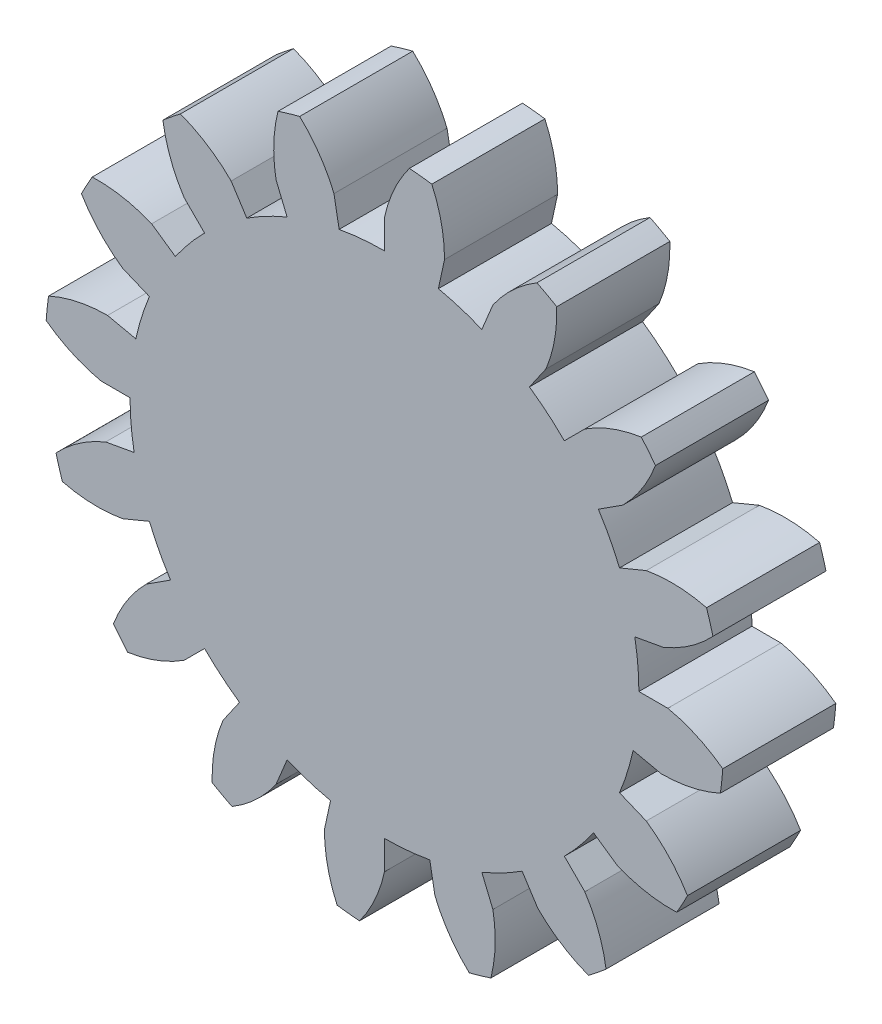
from build123d import *

# Parameters (mm, degrees)
BOSS_EXTRU_1_DEPTH           = 3
R_P_TITION_CIRCULAIRE2_COUNT = 16
ESQUISSE5_R                  = 6.75
BOSS_EXTRU_2_DEPTH           = 3


with BuildPart() as part:
    # Esquisse4 → Boss.-Extru.1 (new body)
    with BuildSketch(Plane.XY):
        with BuildLine():
            Line((0, 7.517540966), (0, 6.75))
            ThreePointArc((0, 6.75), (0.719454333, 6.711548664), (1.430711931, 6.59663273))
            Line((1.430711931, 6.59663273), (1.593397859, 7.346734339))
            ThreePointArc((1.593397859, 7.346734339), (1.508511555, 8.147299885), (1.256427196, 8.911867969))
            ThreePointArc((1.256427196, 8.911867969), (0.959272444, 8.948731551), (0.661055861, 8.975689675))
            ThreePointArc((0.661055861, 8.975689675), (0.252643326, 8.281924527), (0, 7.517540966))
        make_face()
    extrude(amount=BOSS_EXTRU_1_DEPTH)


with BuildPart() as r_p_tition_circulaire2_1:
    # Répétition circulaire2: pattern copy
    add(part.part.rotate(Axis((0, 0, 0), (0, 0, 1)), 1 * 360 / R_P_TITION_CIRCULAIRE2_COUNT))


with BuildPart() as r_p_tition_circulaire2_2:
    # Répétition circulaire2: pattern copy
    add(part.part.rotate(Axis((0, 0, 0), (0, 0, 1)), 2 * 360 / R_P_TITION_CIRCULAIRE2_COUNT))


with BuildPart() as r_p_tition_circulaire2_3:
    # Répétition circulaire2: pattern copy
    add(part.part.rotate(Axis((0, 0, 0), (0, 0, 1)), 3 * 360 / R_P_TITION_CIRCULAIRE2_COUNT))


with BuildPart() as r_p_tition_circulaire2_4:
    # Répétition circulaire2: pattern copy
    add(part.part.rotate(Axis((0, 0, 0), (0, 0, 1)), 4 * 360 / R_P_TITION_CIRCULAIRE2_COUNT))


with BuildPart() as r_p_tition_circulaire2_5:
    # Répétition circulaire2: pattern copy
    add(part.part.rotate(Axis((0, 0, 0), (0, 0, 1)), 5 * 360 / R_P_TITION_CIRCULAIRE2_COUNT))


with BuildPart() as r_p_tition_circulaire2_6:
    # Répétition circulaire2: pattern copy
    add(part.part.rotate(Axis((0, 0, 0), (0, 0, 1)), 6 * 360 / R_P_TITION_CIRCULAIRE2_COUNT))


with BuildPart() as r_p_tition_circulaire2_7:
    # Répétition circulaire2: pattern copy
    add(part.part.rotate(Axis((0, 0, 0), (0, 0, 1)), 7 * 360 / R_P_TITION_CIRCULAIRE2_COUNT))


with BuildPart() as r_p_tition_circulaire2_8:
    # Répétition circulaire2: pattern copy
    add(part.part.rotate(Axis((0, 0, 0), (0, 0, 1)), 8 * 360 / R_P_TITION_CIRCULAIRE2_COUNT))


with BuildPart() as r_p_tition_circulaire2_9:
    # Répétition circulaire2: pattern copy
    add(part.part.rotate(Axis((0, 0, 0), (0, 0, 1)), 9 * 360 / R_P_TITION_CIRCULAIRE2_COUNT))


with BuildPart() as r_p_tition_circulaire2_10:
    # Répétition circulaire2: pattern copy
    add(part.part.rotate(Axis((0, 0, 0), (0, 0, 1)), 10 * 360 / R_P_TITION_CIRCULAIRE2_COUNT))


with BuildPart() as r_p_tition_circulaire2_11:
    # Répétition circulaire2: pattern copy
    add(part.part.rotate(Axis((0, 0, 0), (0, 0, 1)), 11 * 360 / R_P_TITION_CIRCULAIRE2_COUNT))


with BuildPart() as r_p_tition_circulaire2_12:
    # Répétition circulaire2: pattern copy
    add(part.part.rotate(Axis((0, 0, 0), (0, 0, 1)), 12 * 360 / R_P_TITION_CIRCULAIRE2_COUNT))


with BuildPart() as r_p_tition_circulaire2_13:
    # Répétition circulaire2: pattern copy
    add(part.part.rotate(Axis((0, 0, 0), (0, 0, 1)), 13 * 360 / R_P_TITION_CIRCULAIRE2_COUNT))


with BuildPart() as r_p_tition_circulaire2_14:
    # Répétition circulaire2: pattern copy
    add(part.part.rotate(Axis((0, 0, 0), (0, 0, 1)), 14 * 360 / R_P_TITION_CIRCULAIRE2_COUNT))


with BuildPart() as r_p_tition_circulaire2_15:
    # Répétition circulaire2: pattern copy
    add(part.part.rotate(Axis((0, 0, 0), (0, 0, 1)), 15 * 360 / R_P_TITION_CIRCULAIRE2_COUNT))


with BuildPart() as part_1:
    add(part.part)

    add(r_p_tition_circulaire2_1.part)  # Boss.-Extru.2 merges Répétition circulaire2_1

    add(r_p_tition_circulaire2_2.part)  # Boss.-Extru.2 merges Répétition circulaire2_2

    add(r_p_tition_circulaire2_3.part)  # Boss.-Extru.2 merges Répétition circulaire2_3

    add(r_p_tition_circulaire2_4.part)  # Boss.-Extru.2 merges Répétition circulaire2_4

    add(r_p_tition_circulaire2_5.part)  # Boss.-Extru.2 merges Répétition circulaire2_5

    add(r_p_tition_circulaire2_6.part)  # Boss.-Extru.2 merges Répétition circulaire2_6

    add(r_p_tition_circulaire2_7.part)  # Boss.-Extru.2 merges Répétition circulaire2_7

    add(r_p_tition_circulaire2_8.part)  # Boss.-Extru.2 merges Répétition circulaire2_8

    add(r_p_tition_circulaire2_9.part)  # Boss.-Extru.2 merges Répétition circulaire2_9

    add(r_p_tition_circulaire2_10.part)  # Boss.-Extru.2 merges Répétition circulaire2_10

    add(r_p_tition_circulaire2_11.part)  # Boss.-Extru.2 merges Répétition circulaire2_11

    add(r_p_tition_circulaire2_12.part)  # Boss.-Extru.2 merges Répétition circulaire2_12

    add(r_p_tition_circulaire2_13.part)  # Boss.-Extru.2 merges Répétition circulaire2_13

    add(r_p_tition_circulaire2_14.part)  # Boss.-Extru.2 merges Répétition circulaire2_14

    add(r_p_tition_circulaire2_15.part)  # Boss.-Extru.2 merges Répétition circulaire2_15
    # Esquisse5 → Boss.-Extru.2 (add)
    with BuildSketch(Plane.XY):
        Circle(ESQUISSE5_R)
    extrude(amount=BOSS_EXTRU_2_DEPTH)


solid = part_1.part
